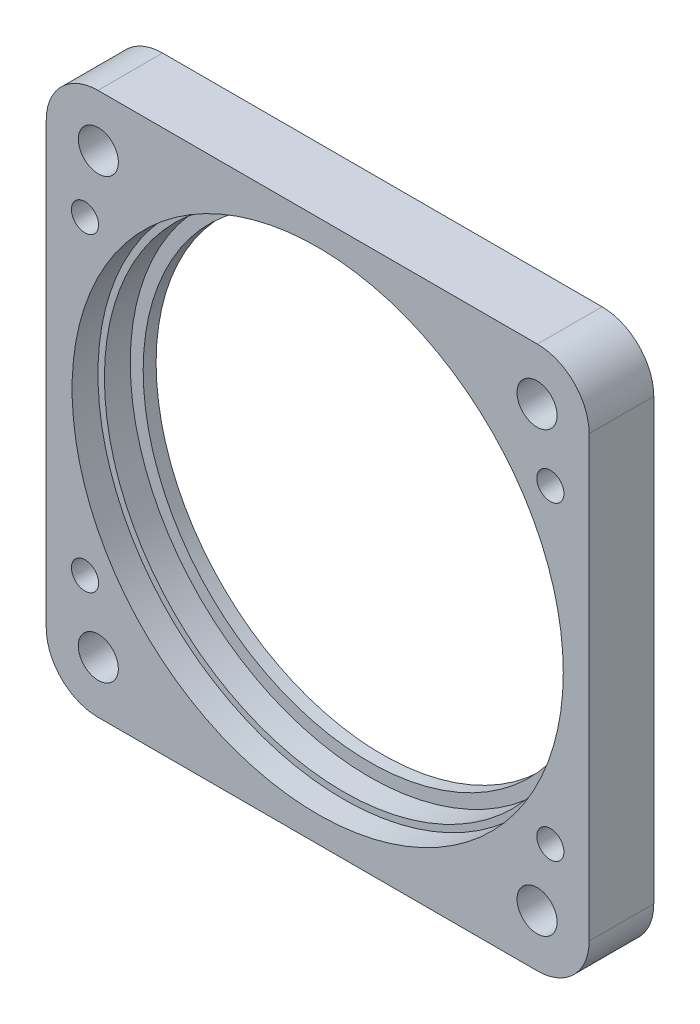
from build123d import *

# Parameters (mm, degrees)
SKETCH_1_W          = 42
SKETCH_1_H          = 42
EXTRUDE_1_DEPTH     = 5
SKETCH_2_R          = 17.5
CUT_EXTRUDE_1_DEPTH = 6
SKETCH_3_R          = 18.5
CUT_EXTRUDE_2_DEPTH = 4
SKETCH_4_R          = 19
CUT_EXTRUDE_3_DEPTH = 2
FILLET_1_R          = 4
SKETCH_5_R          = 1.55
CUT_EXTRUDE_4_DEPTH = 6
SKETCH_7_R          = 1.05
CUT_EXTRUDE_5_DEPTH = 6
SKETCH_8_R          = 2
CUT_EXTRUDE_6_DEPTH = 3


with BuildPart() as part:
    # 草图1 → 凸台-拉伸1 (new body)
    with BuildSketch(Plane.XY):
        Rectangle(SKETCH_1_W, SKETCH_1_H)
    extrude(amount=EXTRUDE_1_DEPTH)

    # 草图2 → 切除-拉伸1 (cut, through all)
    with BuildSketch(Plane.XY.offset(5)):
        Circle(SKETCH_2_R)
    extrude(amount=-CUT_EXTRUDE_1_DEPTH, mode=Mode.SUBTRACT)

    # 草图3 → 切除-拉伸2 (cut)
    with BuildSketch(Plane.XY.offset(5)):
        Circle(SKETCH_3_R)
    extrude(amount=-CUT_EXTRUDE_2_DEPTH, mode=Mode.SUBTRACT)

    # 草图4 → 切除-拉伸3 (cut)
    with BuildSketch(Plane.XY.offset(5)):
        Circle(SKETCH_4_R)
    extrude(amount=-CUT_EXTRUDE_3_DEPTH, mode=Mode.SUBTRACT)

    # 圆角1
    fillet_1_edges = [part.edges().sort_by_distance(p)[0] for p in [
        (21, -21, 2.5),
        (-21, -21, 2.5),
        (-21, 21, 2.5),
        (21, 21, 2.5),
    ]]
    fillet(fillet_1_edges, radius=FILLET_1_R)

    # 草图5 → 切除-拉伸4 (cut, through all)
    with BuildSketch(Plane.XY.offset(5)):
        with Locations((-16.970562748, 16.970562748)):
            Circle(SKETCH_5_R)
        with Locations((16.970562748, 16.970562748)):
            Circle(SKETCH_5_R)
        with Locations((16.970562748, -16.970562748)):
            Circle(SKETCH_5_R)
        with Locations((-16.970562748, -16.970562748)):
            Circle(SKETCH_5_R)
    extrude(amount=-CUT_EXTRUDE_4_DEPTH, mode=Mode.SUBTRACT)

    # 草图7 → 切除-拉伸5 (cut, through all)
    with BuildSketch(Plane(origin=(0, 0, 0), x_dir=(-1, 0, 0), z_dir=(0, 0, -1))):
        with Locations((-18, 12)):
            Circle(SKETCH_7_R)
        with Locations((18, 12)):
            Circle(SKETCH_7_R)
        with Locations((18, -12)):
            Circle(SKETCH_7_R)
        with Locations((-18, -12)):
            Circle(SKETCH_7_R)
    extrude(amount=-CUT_EXTRUDE_5_DEPTH, mode=Mode.SUBTRACT)

    # 草图8 → 切除-拉伸6 (cut)
    with BuildSketch(Plane(origin=(0, 0, 0), x_dir=(-1, 0, 0), z_dir=(0, 0, -1))):
        with Locations((-18, 12)):
            Circle(SKETCH_8_R)
        with Locations((18, 12)):
            Circle(SKETCH_8_R)
        with Locations((18, -12)):
            Circle(SKETCH_8_R)
        with Locations((-18, -12)):
            Circle(SKETCH_8_R)
    extrude(amount=-CUT_EXTRUDE_6_DEPTH, mode=Mode.SUBTRACT)


solid = part.part
